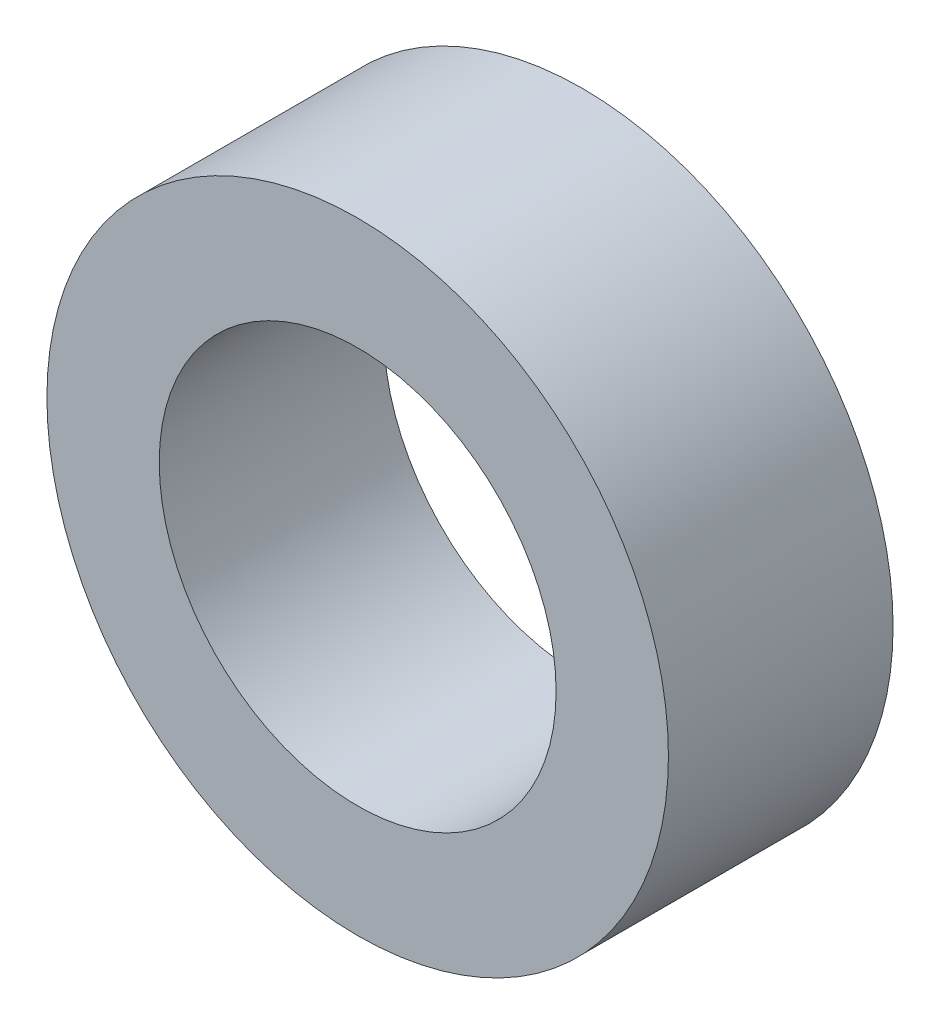
from build123d import *

# Parameters (mm, degrees)
SKETCH1_R           = 4.15
SKETCH1_R_2         = 2.65
BOSS_EXTRUDE1_DEPTH = 3


with BuildPart() as part:
    # Sketch1 → Boss-Extrude1 (new body)
    with BuildSketch(Plane.XY):
        Circle(SKETCH1_R)
        Circle(SKETCH1_R_2, mode=Mode.SUBTRACT)
    extrude(amount=BOSS_EXTRUDE1_DEPTH)


solid = part.part
